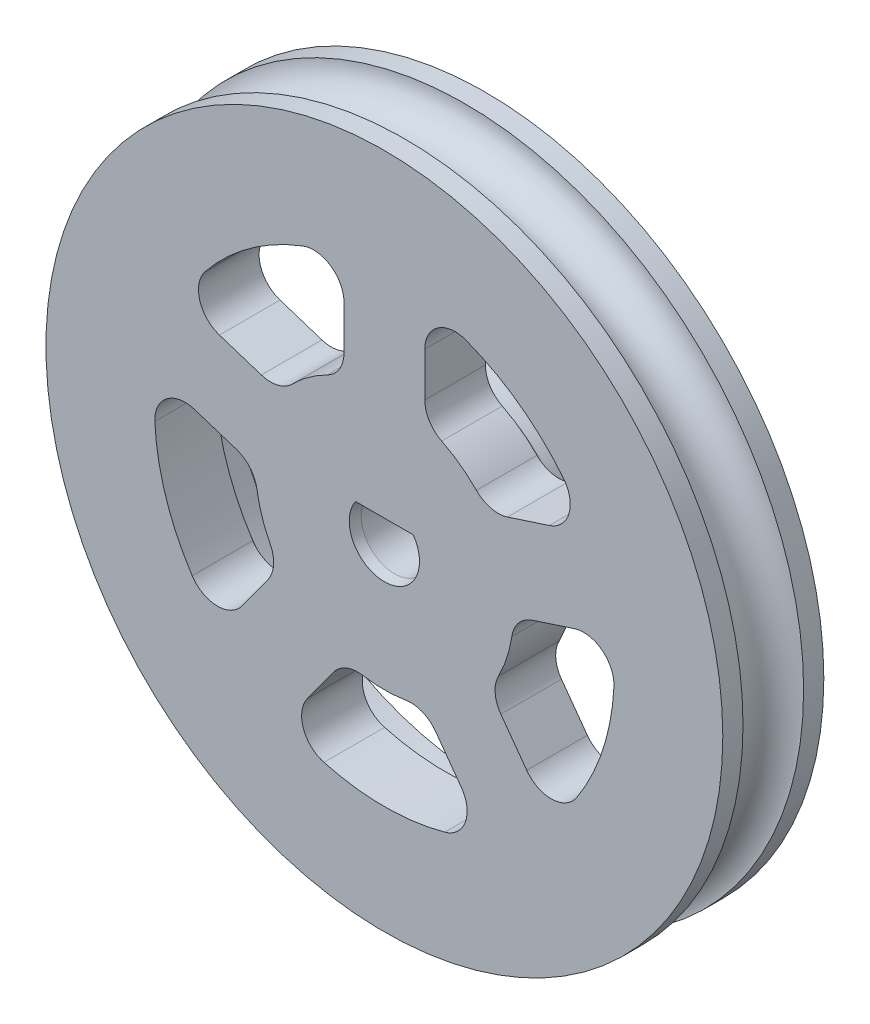
from build123d import *
from OCP.BRepFilletAPI import BRepFilletAPI_MakeChamfer

# Parameters (mm, degrees)
SKETCH7_R           = 12.75
CUT_EXTRUDE3_DEPTH  = 2
SKETCH8_R           = 5
BOSS_EXTRUDE1_DEPTH = 5
CUT_EXTRUDE4_DEPTH  = 26.002499875
FILLET1_R           = 1
CHAMFER1_SIZE       = 0.5
CHAMFER1_SIZE2      = 0.08816349
CHAMFER2_SIZE       = 0.5
CHAMFER2_SIZE2      = 0.08816349
CUT_EXTRUDE7_DEPTH  = 25.210018587
FILLET3_R           = 1.5


with BuildPart() as part:
    # Sketch3 → Revolve1 (revolve)
    with BuildSketch(Plane(origin=(0, 0, 0), x_dir=(1, 0, 0), z_dir=(0, 1, 0)), mode=Mode.PRIVATE) as revolve1_sk:
        with BuildLine():
            Line((0, -2.5), (0, 2.5))
            Line((0, 2.5), (-16.75, 2.5))
            Line((-16.75, 2.5), (-16.75, 1.5))
            ThreePointArc((-16.75, 1.5), (-15.25, 0), (-16.75, -1.5))
            Line((-16.75, -1.5), (-16.75, -2.5))
            Line((-16.75, -2.5), (0, -2.5))
        make_face()
    revolve(revolve1_sk.sketch.rotate(Axis((0, 0, 2.5), (0, 0, -1)), 180), axis=Axis((0, 0, 2.5), (0, 0, -1)))

    # Sketch7 → Cut-Extrude3 (cut)
    with BuildSketch(Plane.XY.offset(-2.5)):
        Circle(SKETCH7_R)
    extrude(amount=CUT_EXTRUDE3_DEPTH, mode=Mode.SUBTRACT)

    # Sketch8 → Boss-Extrude1 (add)
    with BuildSketch(Plane.XY.offset(-0.5)):
        Circle(SKETCH8_R)
    extrude(amount=-BOSS_EXTRUDE1_DEPTH)

    # Sketch6 → Cut-Extrude4 (cut, through all)
    with BuildSketch(Plane.XY.offset(-5.5)):
        with BuildLine():
            Line((-1.382931669, 0.9), (1.382931669, 0.9))
            ThreePointArc((1.382931669, 0.9), (0, -1.65), (-1.382931669, 0.9))
        make_face()
    extrude(amount=CUT_EXTRUDE4_DEPTH, mode=Mode.SUBTRACT)

    # Fillet1
    fillet1_edges = [part.edges().sort_by_distance(p)[0] for p in [
        (-12.75, 0, -0.5),
        (-5, 0, -0.5),
    ]]
    fillet(fillet1_edges, radius=FILLET1_R)

    # Chamfer1: one chamfer whose edges measure the first distance from different faces: ONE call of the kernel's chamfer builder (chamfer() names one face for all edges)
    chamfer1_edges_1 = [part.edges().sort_by_distance(p)[0] for p in [
        (0, -1.65, -5.5),
    ]]
    chamfer1_side_1 = [part.faces().sort_by_distance(p)[0] for p in [
        (0, -1.65, -1.5),
    ]]
    chamfer1_edges_2 = [part.edges().sort_by_distance(p)[0] for p in [
        (0, 0.9, -5.5),
    ]]
    chamfer1_side_2 = [part.faces().sort_by_distance(p)[0] for p in [
        (0, 0.9, -1.5),
    ]]
    chamfer1 = BRepFilletAPI_MakeChamfer(part.part.solid().wrapped)
    for e in chamfer1_edges_1:
        chamfer1.Add(CHAMFER1_SIZE, CHAMFER1_SIZE2, e.wrapped, chamfer1_side_1[0].wrapped)  # the first distance lies on this face
    for e in chamfer1_edges_2:
        chamfer1.Add(CHAMFER1_SIZE, CHAMFER1_SIZE2, e.wrapped, chamfer1_side_2[0].wrapped)  # the first distance lies on this face
    add(Compound.cast(chamfer1.Shape()), mode=Mode.REPLACE)

    # Chamfer2: one chamfer whose edges measure the first distance from different faces: ONE call of the kernel's chamfer builder (chamfer() names one face for all edges)
    chamfer2_edges_1 = [part.edges().sort_by_distance(p)[0] for p in [
        (0, 0.9, 2.5),
    ]]
    chamfer2_side_1 = [part.faces().sort_by_distance(p)[0] for p in [
        (0, 0.9, -1.25),
    ]]
    chamfer2_edges_2 = [part.edges().sort_by_distance(p)[0] for p in [
        (0, -1.65, 2.5),
    ]]
    chamfer2_side_2 = [part.faces().sort_by_distance(p)[0] for p in [
        (0, -1.65, -1.25),
    ]]
    chamfer2 = BRepFilletAPI_MakeChamfer(part.part.solid().wrapped)
    for e in chamfer2_edges_1:
        chamfer2.Add(CHAMFER2_SIZE, CHAMFER2_SIZE2, e.wrapped, chamfer2_side_1[0].wrapped)  # the first distance lies on this face
    for e in chamfer2_edges_2:
        chamfer2.Add(CHAMFER2_SIZE, CHAMFER2_SIZE2, e.wrapped, chamfer2_side_2[0].wrapped)  # the first distance lies on this face
    add(Compound.cast(chamfer2.Shape()), mode=Mode.REPLACE)

    # Sketch11 → Cut-Extrude7 (cut, through all)
    with BuildSketch(Plane(origin=(0, 0, -0.5), x_dir=(-1, 0, 0), z_dir=(0, 0, -1))):
        with BuildLine():
            Line((-2, 6.053150006), (-2, 11.197795542))
            ThreePointArc((-2, 11.197795542), (-6.686057245, 9.202568311), (-10.03170243, 5.362422155))
            Line((-10.03170243, 5.362422155), (-5.138853769, 3.772639254))
            ThreePointArc((-5.138853769, 3.772639254), (-3.747130983, 5.157483339), (-2, 6.053150006))
        make_face()
        with BuildLine():
            ThreePointArc((10.03170243, 5.362422155), (6.686057245, 9.202568311), (2, 11.197795542))
            Line((2, 11.197795542), (2, 6.053150006))
            ThreePointArc((2, 6.053150006), (3.747130983, 5.157483339), (5.138853769, 3.772639254))
            Line((5.138853769, 3.772639254), (10.03170243, 5.362422155))
        make_face()
        with BuildLine():
            Line((-6.374921746, -0.031586811), (-11.267770407, 1.558196089))
            ThreePointArc((-11.267770407, 1.558196089), (-10.818267873, -3.515068311), (-8.199933067, -7.883636388))
            Line((-8.199933067, -7.883636388), (-5.175986292, -3.72153072))
            ThreePointArc((-5.175986292, -3.72153072), (-6.062985291, -1.969983339), (-6.374921746, -0.031586811))
        make_face()
        with BuildLine():
            ThreePointArc((11.375, 0), (11.348160939, 0.780940657), (11.267770407, 1.558196089))
            Line((11.267770407, 1.558196089), (6.374921746, -0.031586811))
            ThreePointArc((6.374921746, -0.031586811), (6.062985291, -1.969983339), (5.175986292, -3.72153072))
            Line((5.175986292, -3.72153072), (8.199933067, -7.883636388))
            ThreePointArc((8.199933067, -7.883636388), (10.551418474, -4.249493286), (11.375, 0))
        make_face()
        with BuildLine():
            Line((-1.939918315, -6.072671729), (-4.963865089, -10.234777398))
            ThreePointArc((-4.963865089, -10.234777398), (0, -11.375), (4.963865089, -10.234777398))
            Line((4.963865089, -10.234777398), (1.939918315, -6.072671729))
            ThreePointArc((1.939918315, -6.072671729), (0, -6.375), (-1.939918315, -6.072671729))
        make_face()
    extrude(amount=-CUT_EXTRUDE7_DEPTH, mode=Mode.SUBTRACT)

    # Fillet3
    fillet3_edges = [part.edges().sort_by_distance(p)[0] for p in [
        (-5.138853769, 3.772639254, 1),
        (-2, 6.053150006, 1),
        (-2, 11.197795542, 1),
        (-10.03170243, 5.362422155, 1),
        (6.374921746, -0.031586811, 1),
        (5.175986292, -3.72153072, 1),
        (8.199933067, -7.883636388, 1),
        (11.267770407, 1.558196089, 1),
        (-5.175986292, -3.72153072, 1),
        (-6.374921746, -0.031586811, 1),
        (-11.267770407, 1.558196089, 1),
        (-8.199933067, -7.883636388, 1),
        (1.939918315, -6.072671729, 1),
        (-1.939918315, -6.072671729, 1),
        (-4.963865089, -10.234777398, 1),
        (4.963865089, -10.234777398, 1),
        (2, 6.053150006, 1),
        (5.138853769, 3.772639254, 1),
        (10.03170243, 5.362422155, 1),
        (2, 11.197795542, 1),
    ]]
    fillet(fillet3_edges, radius=FILLET3_R)


solid = part.part
